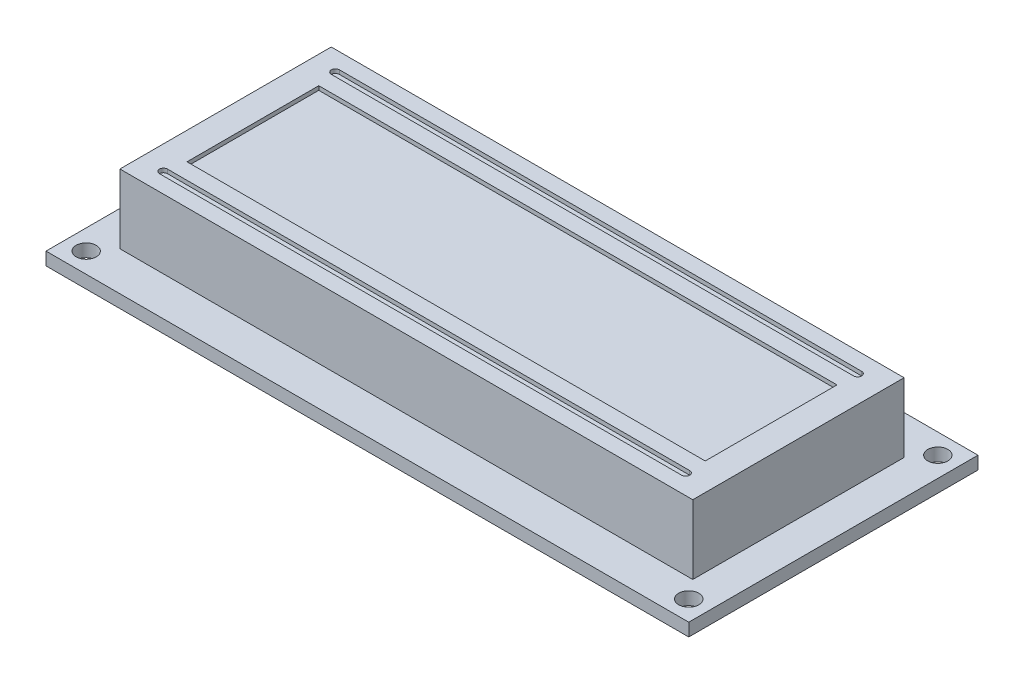
from build123d import *

# Parameters (mm, degrees)
SKETCH1_W                = 80
SKETCH1_H                = 36
SKETCH1_R                = 1.25
SKETCH1_R_2              = 0.5
BOSS_EXTRUDE1_DEPTH      = 1.6
SKETCH2_W                = 71.3
SKETCH2_H                = 26.3
BOSS_EXTRUDE2_DEPTH      = 8.6
SKETCH3_W                = 64.5
SKETCH3_H                = 16.4
CUT_EXTRUDE1_DEPTH       = 0.5
CUT_EXTRUDE2_DEPTH       = 0.5
SKETCH5_W                = 40.64
SKETCH5_H                = 2.54
BOSS_EXTRUDE3_DEPTH      = 2.54
SKETCH6_R                = 0.5
BOSS_EXTRUDE4_DEPTH      = 11.5
BOSS_EXTRUDE4_DEPTH_BACK = 4.54
SKETCH7_W                = 40.64
SKETCH7_H                = 2.54
BOSS_EXTRUDE5_DEPTH      = 8.5


with BuildPart() as part:
    # Sketch1 → Boss-Extrude1 (new body)
    with BuildSketch(Plane(origin=(0, 0, 0), x_dir=(1, 0, 0), z_dir=(0, 1, 0))):
        Rectangle(SKETCH1_W, SKETCH1_H)
        with Locations((-37.5, 15.5)):
            Circle(SKETCH1_R, mode=Mode.SUBTRACT)
        with Locations((37.5, 15.5)):
            Circle(SKETCH1_R, mode=Mode.SUBTRACT)
        with Locations((37.5, -15.5)):
            Circle(SKETCH1_R, mode=Mode.SUBTRACT)
        with Locations((-37.5, -15.5)):
            Circle(SKETCH1_R, mode=Mode.SUBTRACT)
        with Locations((-32, 16.25)):
            Circle(SKETCH1_R_2, mode=Mode.SUBTRACT)
        with Locations((-29.46, 16.25)):
            Circle(SKETCH1_R_2, mode=Mode.SUBTRACT)
        with Locations((-26.92, 16.25)):
            Circle(SKETCH1_R_2, mode=Mode.SUBTRACT)
        with Locations((-24.38, 16.25)):
            Circle(SKETCH1_R_2, mode=Mode.SUBTRACT)
        with Locations((-21.84, 16.25)):
            Circle(SKETCH1_R_2, mode=Mode.SUBTRACT)
        with Locations((-19.3, 16.25)):
            Circle(SKETCH1_R_2, mode=Mode.SUBTRACT)
        with Locations((-16.76, 16.25)):
            Circle(SKETCH1_R_2, mode=Mode.SUBTRACT)
        with Locations((-14.22, 16.25)):
            Circle(SKETCH1_R_2, mode=Mode.SUBTRACT)
        with Locations((-11.68, 16.25)):
            Circle(SKETCH1_R_2, mode=Mode.SUBTRACT)
        with Locations((-9.14, 16.25)):
            Circle(SKETCH1_R_2, mode=Mode.SUBTRACT)
        with Locations((-6.6, 16.25)):
            Circle(SKETCH1_R_2, mode=Mode.SUBTRACT)
        with Locations((-4.06, 16.25)):
            Circle(SKETCH1_R_2, mode=Mode.SUBTRACT)
        with Locations((-1.52, 16.25)):
            Circle(SKETCH1_R_2, mode=Mode.SUBTRACT)
        with Locations((1.02, 16.25)):
            Circle(SKETCH1_R_2, mode=Mode.SUBTRACT)
        with Locations((3.56, 16.25)):
            Circle(SKETCH1_R_2, mode=Mode.SUBTRACT)
        with Locations((6.1, 16.25)):
            Circle(SKETCH1_R_2, mode=Mode.SUBTRACT)
    extrude(amount=BOSS_EXTRUDE1_DEPTH)

    # Sketch2 → Boss-Extrude2 (add)
    with BuildSketch(Plane(origin=(0, 1.6, 0), x_dir=(1, 0, 0), z_dir=(0, 1, 0))):
        Rectangle(SKETCH2_W, SKETCH2_H)
    extrude(amount=BOSS_EXTRUDE2_DEPTH)

    # Sketch3 → Cut-Extrude1 (cut)
    with BuildSketch(Plane(origin=(0, 10.2, 0), x_dir=(1, 0, 0), z_dir=(0, 1, 0))):
        Rectangle(SKETCH3_W, SKETCH3_H)
    extrude(amount=-CUT_EXTRUDE1_DEPTH, mode=Mode.SUBTRACT)

    # Sketch4 → Cut-Extrude2 (cut)
    with BuildSketch(Plane(origin=(0, 10.2, 0), x_dir=(1, 0, 0), z_dir=(0, 1, 0))):
        with BuildLine():
            Line((-32.681461103, 10.2), (32.318538897, 10.2))
            ThreePointArc((32.318538897, 10.2), (32.818538897, 10.7), (32.318538897, 11.2))
            Line((32.318538897, 11.2), (-32.681461103, 11.2))
            ThreePointArc((-32.681461103, 11.2), (-33.181461103, 10.7), (-32.681461103, 10.2))
        make_face()
    cut_extrude2 = extrude(amount=-CUT_EXTRUDE2_DEPTH, mode=Mode.SUBTRACT)

    # Mirror1: Cut-Extrude2 across plane
    add(cut_extrude2.mirror(Plane.XY), mode=Mode.SUBTRACT)

    # Sketch5 → Boss-Extrude3 (add)
    with BuildSketch(Plane.XZ):
        with Locations((-12.95, -16.25)):
            Rectangle(SKETCH5_W, SKETCH5_H)
    extrude(amount=BOSS_EXTRUDE3_DEPTH)

    # Sketch6 → Boss-Extrude4 (add, two sides)
    with BuildSketch(Plane.XZ.offset(2.54)) as boss_extrude4_sk:
        with Locations((-32, -16.25)):
            Circle(SKETCH6_R)
        with Locations((-29.46, -16.25)):
            Circle(SKETCH6_R)
        with Locations((-26.92, -16.25)):
            Circle(SKETCH6_R)
        with Locations((-24.38, -16.25)):
            Circle(SKETCH6_R)
        with Locations((-21.84, -16.25)):
            Circle(SKETCH6_R)
        with Locations((-19.3, -16.25)):
            Circle(SKETCH6_R)
        with Locations((-16.76, -16.25)):
            Circle(SKETCH6_R)
        with Locations((-14.22, -16.25)):
            Circle(SKETCH6_R)
        with Locations((-11.68, -16.25)):
            Circle(SKETCH6_R)
        with Locations((-9.14, -16.25)):
            Circle(SKETCH6_R)
        with Locations((-6.6, -16.25)):
            Circle(SKETCH6_R)
        with Locations((-4.06, -16.25)):
            Circle(SKETCH6_R)
        with Locations((-1.52, -16.25)):
            Circle(SKETCH6_R)
        with Locations((1.02, -16.25)):
            Circle(SKETCH6_R)
        with Locations((3.56, -16.25)):
            Circle(SKETCH6_R)
        with Locations((6.1, -16.25)):
            Circle(SKETCH6_R)
    extrude(amount=BOSS_EXTRUDE4_DEPTH)
    extrude(boss_extrude4_sk.sketch, amount=-BOSS_EXTRUDE4_DEPTH_BACK)

    # Sketch7 → Boss-Extrude5 (add)
    with BuildSketch(Plane.XZ.offset(2.54)):
        with Locations((-12.95, -16.25)):
            Rectangle(SKETCH7_W, SKETCH7_H)
    extrude(amount=BOSS_EXTRUDE5_DEPTH)


solid = part.part
